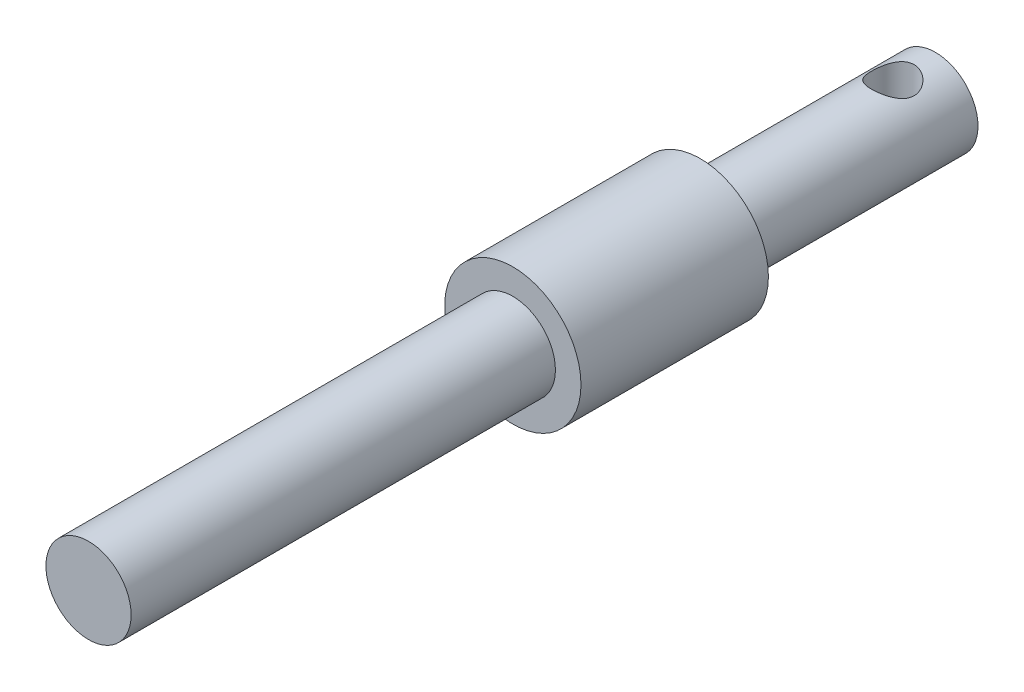
from build123d import *

# Parameters (mm, degrees)
SKETCH1_R               = 2.5
BOSS_EXTRUDE1_DEPTH     = 13.8
BOSS_EXTRUDE3_START     = 13.8
SKETCH1_4_R             = 4
BOSS_EXTRUDE3_DEPTH     = 11
BOSS_EXTRUDE2_START     = 24.8
SKETCH1_3_R             = 2.5
BOSS_EXTRUDE2_DEPTH     = 24.9
SKETCH17_R              = 1.25
CUT_EXTRUDE1_DEPTH      = 5
CUT_EXTRUDE1_DEPTH_BACK = 5


with BuildPart() as part:
    # Sketch1 → Boss-Extrude1 (new body)
    with BuildSketch(Plane.XY):
        Circle(SKETCH1_R)
    extrude(amount=BOSS_EXTRUDE1_DEPTH)

    # Sketch1_4 → Boss-Extrude3 (add)
    with BuildSketch(Plane.XY.offset(BOSS_EXTRUDE3_START)):
        Circle(SKETCH1_4_R)
    extrude(amount=BOSS_EXTRUDE3_DEPTH)

    # Sketch1_3 → Boss-Extrude2 (add)
    with BuildSketch(Plane.XY.offset(BOSS_EXTRUDE2_START)):
        Circle(SKETCH1_3_R)
    extrude(amount=BOSS_EXTRUDE2_DEPTH)

    # Sketch17 → Cut-Extrude1 (cut, two sides)
    with BuildSketch(Plane(origin=(0, 0, 0), x_dir=(1, 0, 0), z_dir=(0, 1, 0))) as cut_extrude1_sk:
        with Locations((0, -2.5)):
            Circle(SKETCH17_R)
    extrude(amount=CUT_EXTRUDE1_DEPTH, mode=Mode.SUBTRACT)
    extrude(cut_extrude1_sk.sketch, amount=-CUT_EXTRUDE1_DEPTH_BACK, mode=Mode.SUBTRACT)


solid = part.part
